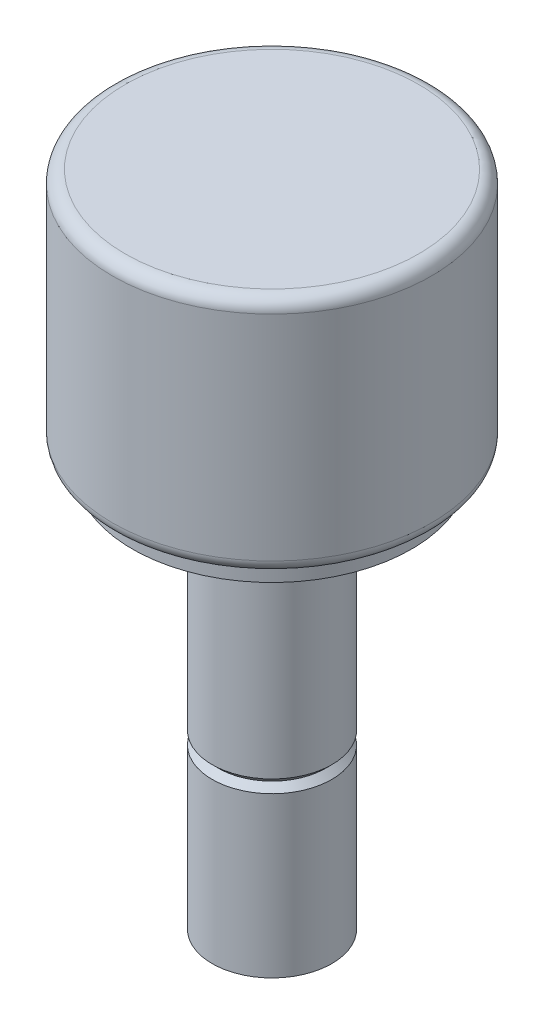
from build123d import *

# Parameters (mm, degrees)
FILLET1_R = 0.508


with BuildPart() as part:
    # Sketch1 → Revolve1 (revolve)
    with BuildSketch(Plane.XY, mode=Mode.PRIVATE) as revolve1_sk:
        Polygon((0, 0), (2.38125, 0), (2.38125, 6.35), (2.12725, 6.604), (2.38125, 6.858), (2.38125, 15.875), (5.55625, 15.875), (5.55625, 16.66875), (6.35, 16.66875), (6.35, 26.19375), (0, 26.19375), align=None)
    revolve(revolve1_sk.sketch.rotate(Axis((0, 0, 0), (0, 1, 0)), 90), axis=Axis((0, 0, 0), (0, 1, 0)))  # turned: the seam where the file's is

    # Fillet1
    fillet1_edges = [part.edges().sort_by_distance(p)[0] for p in [
        (0, 26.19375, 6.35),
        (0, 16.66875, 6.35),
    ]]
    fillet(fillet1_edges, radius=FILLET1_R)


solid = part.part
